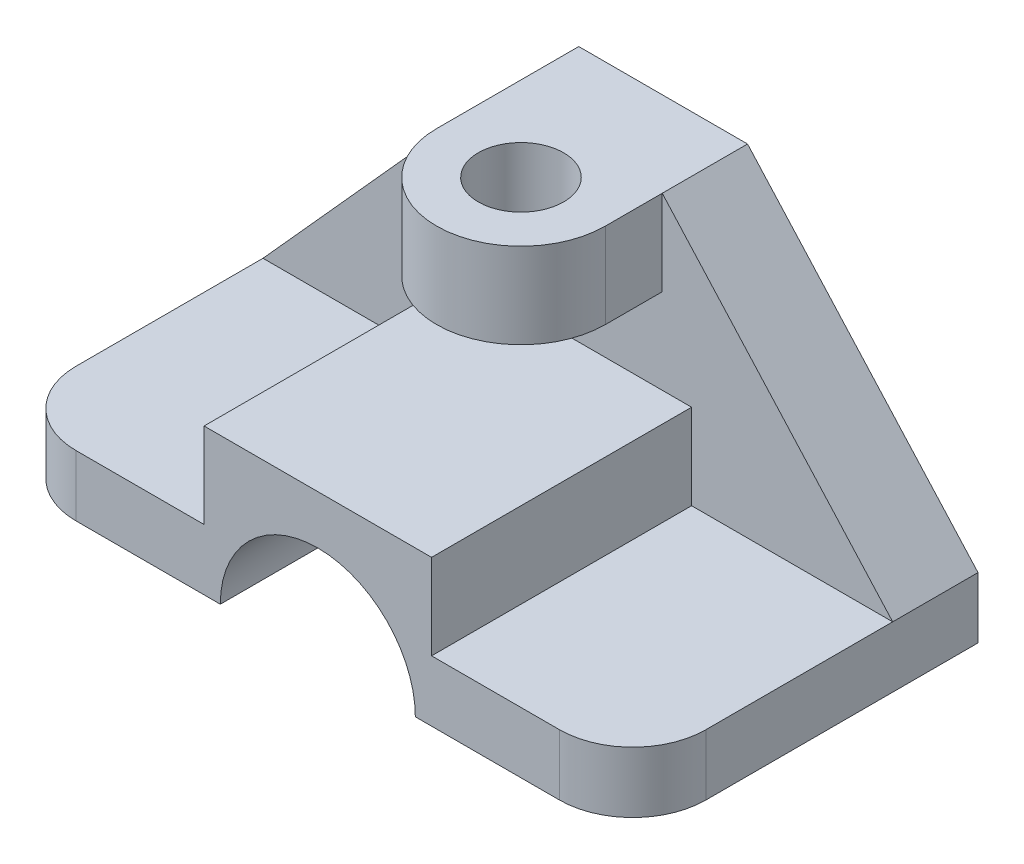
from build123d import *

# Parameters (mm, degrees)
SKETCH2_W           = 155
SKETCH2_H           = 78
BOSS_EXTRUDE1_DEPTH = 21
BOSS_EXTRUDE2_DEPTH = 64
FILLET1_R           = 18
CUT_EXTRUDE1_DEPTH  = 22
SKETCH5_R           = 10.5
BOSS_EXTRUDE3_DEPTH = 21


with BuildPart() as part:
    # Sketch2 → Boss-Extrude1 (new body)
    with BuildSketch(Plane.XY):
        with Locations((77.5, 39)):
            Rectangle(SKETCH2_W, SKETCH2_H)
    extrude(amount=BOSS_EXTRUDE1_DEPTH)

    # Sketch3 → Boss-Extrude2 (add)
    with BuildSketch(Plane.XY.offset(21)):
        with BuildLine():
            Line((0, 0), (53.5, 0))
            ThreePointArc((53.5, 0), (77.5, 24), (101.5, 0))
            Line((101.5, 0), (155, 0))
            Line((155, 0), (155, 15))
            Line((155, 15), (105.5, 15))
            Line((105.5, 15), (105.5, 36))
            Line((105.5, 36), (49.5, 36))
            Line((49.5, 36), (49.5, 15))
            Line((49.5, 15), (0, 15))
            Line((0, 15), (0, 0))
        make_face()
    extrude(amount=BOSS_EXTRUDE2_DEPTH)

    # Fillet1
    fillet1_edges = [part.edges().sort_by_distance(p)[0] for p in [
        (0, 7.5, 85),
        (155, 7.5, 85),
    ]]
    fillet(fillet1_edges, radius=FILLET1_R)

    # Sketch4 → Cut-Extrude1 (cut, through all)
    with BuildSketch(Plane.XY.offset(21)):
        Polygon((0, 15), (56.725454791, 78), (0, 78), align=None)
        Polygon((155, 15), (98.274545209, 78), (155, 78), align=None)
    extrude(amount=-CUT_EXTRUDE1_DEPTH, mode=Mode.SUBTRACT)

    # Sketch5 → Boss-Extrude3 (add)
    with BuildSketch(Plane(origin=(0, 78, 0), x_dir=(1, 0, 0), z_dir=(0, 1, 0))):
        with BuildLine():
            Line((56.725454791, 0), (56.725454791, -35))
            ThreePointArc((56.725454791, -35), (77.5, -55.774545209), (98.274545209, -35))
            Line((98.274545209, -35), (98.274545209, 0))
            Line((98.274545209, 0), (56.725454791, 0))
        make_face()
        with Locations((77.5, -35)):
            Circle(SKETCH5_R, mode=Mode.SUBTRACT)
    extrude(amount=-BOSS_EXTRUDE3_DEPTH)


solid = part.part
